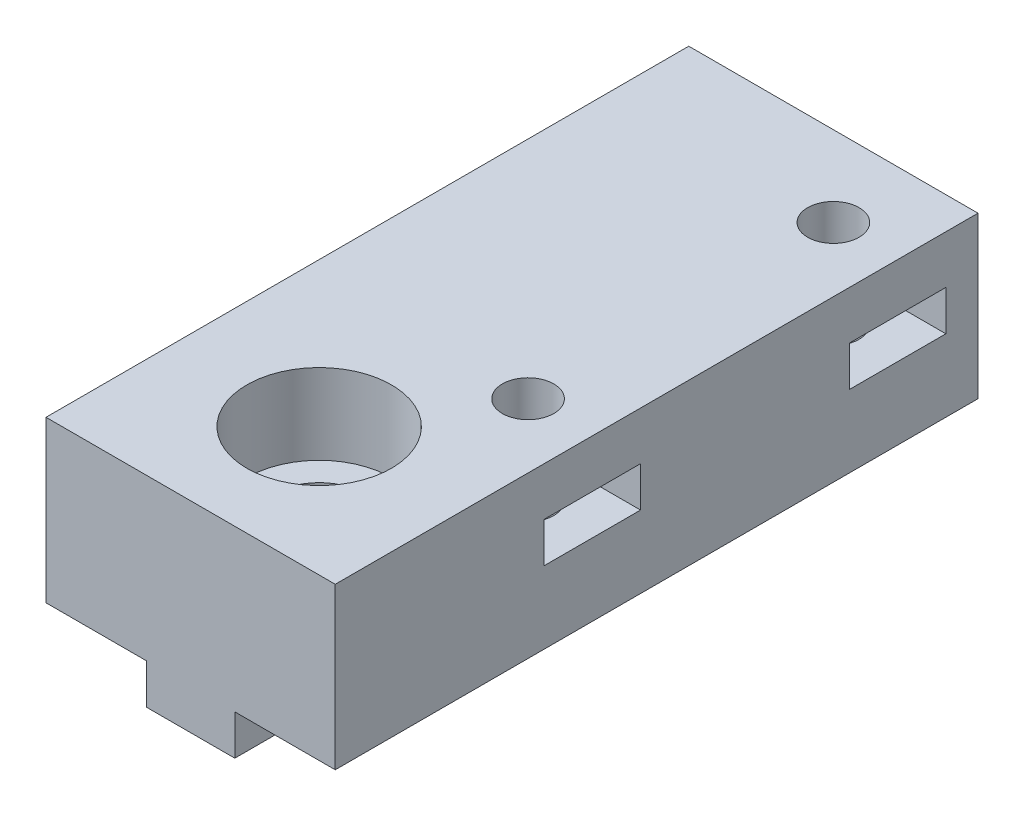
from build123d import *

# Parameters (mm, degrees)
SKETCH1_W           = 18
SKETCH1_H           = 40
BOSS_EXTRUDE1_DEPTH = 10
SKETCH3_W           = 5.5
SKETCH3_H           = 40
BOSS_EXTRUDE5_DEPTH = 2.5
SKETCH2_R           = 2.8
CUT_EXTRUDE1_DEPTH  = 13.5
SKETCH4_R           = 4.5
CUT_EXTRUDE2_DEPTH  = 5
SKETCH5_R           = 1.6
CUT_EXTRUDE3_DEPTH  = 13.5
SKETCH6_W           = 6
SKETCH6_H           = 2.5
CUT_EXTRUDE4_DEPTH  = 8


with BuildPart() as part:
    # Sketch1 → Boss-Extrude1 (new body)
    with BuildSketch(Plane(origin=(0, 0, 0), x_dir=(1, 0, 0), z_dir=(0, 1, 0))):
        with Locations((8.30324178, 20)):
            Rectangle(SKETCH1_W, SKETCH1_H)
    extrude(amount=BOSS_EXTRUDE1_DEPTH)

    # Sketch3 → Boss-Extrude5 (add)
    with BuildSketch(Plane.XZ):
        with Locations((8.30324178, -20)):
            Rectangle(SKETCH3_W, SKETCH3_H)
    extrude(amount=BOSS_EXTRUDE5_DEPTH)

    # Sketch2 → Cut-Extrude1 (cut, through all)
    with BuildSketch(Plane(origin=(0, 10, 0), x_dir=(1, 0, 0), z_dir=(0, 1, 0))):
        with Locations((8.30324178, 8)):
            Circle(SKETCH2_R)
    extrude(amount=-CUT_EXTRUDE1_DEPTH, mode=Mode.SUBTRACT)

    # Sketch4 → Cut-Extrude2 (cut)
    with BuildSketch(Plane(origin=(0, 10, 0), x_dir=(1, 0, 0), z_dir=(0, 1, 0))):
        with Locations((8.30324178, 8)):
            Circle(SKETCH4_R)
    extrude(amount=-CUT_EXTRUDE2_DEPTH, mode=Mode.SUBTRACT)

    # Sketch5 → Cut-Extrude3 (cut, through all)
    with BuildSketch(Plane(origin=(0, 10, 0), x_dir=(1, 0, 0), z_dir=(0, 1, 0))):
        with Locations((13.30324178, 16)):
            Circle(SKETCH5_R)
        with Locations((13.30324178, 35)):
            Circle(SKETCH5_R)
    extrude(amount=-CUT_EXTRUDE3_DEPTH, mode=Mode.SUBTRACT)

    # Sketch6 → Cut-Extrude4 (cut)
    with BuildSketch(Plane(origin=(17.30324178, 0, 0), x_dir=(0, 0, -1), z_dir=(1, 0, 0))):
        with Locations((16, 5.75)):
            Rectangle(SKETCH6_W, SKETCH6_H)
        with Locations((35, 5.75)):
            Rectangle(SKETCH6_W, SKETCH6_H)
    extrude(amount=-CUT_EXTRUDE4_DEPTH, mode=Mode.SUBTRACT)


solid = part.part
